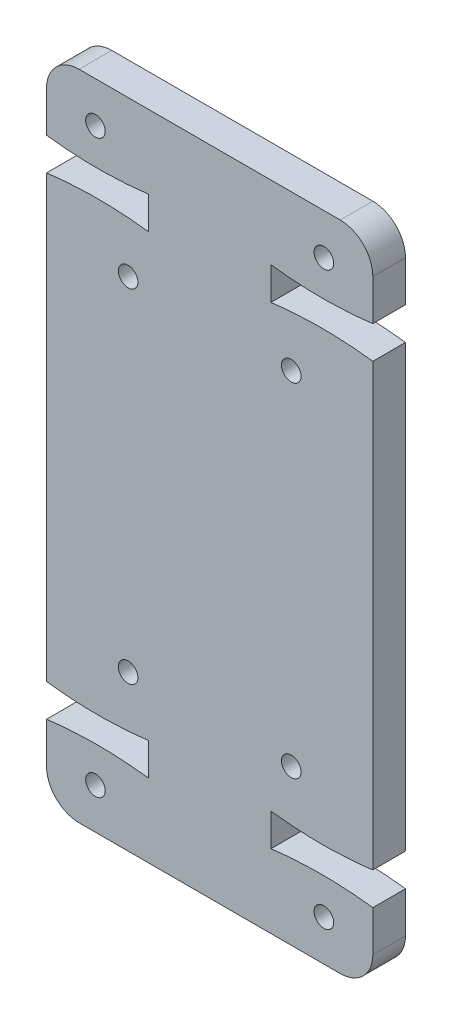
from build123d import *

# Parameters (mm, degrees)
SKETCH1_R               = 0.6
FINGER_PIP_BODY_DEPTH   = 2
FINGER_PIP_CONTOURING_R = 2


with BuildPart() as part:
    # Sketch1 → Finger PIP Body (new body)
    with BuildSketch(Plane.XY):
        with BuildLine():
            Line((0, 6.5), (0, 33.5))
            add(Edge.make_bspline(
                [(0, 33.5), (3.125, 33.9), (6.25, 33.5)],
                knots=[0, 0, 0, 1, 1, 1], degree=2))
            Line((6.25, 33.5), (6.25, 35.5))
            add(Edge.make_bspline(
                [(0, 35.5), (3.125, 35.1), (6.25, 35.5)],
                knots=[0, 0, 0, 1, 1, 1], degree=2))
            Line((0, 35.5), (0, 40))
            Line((0, 40), (20, 40))
            Line((20, 40), (20, 35.5))
            add(Edge.make_bspline(
                [(20, 35.5), (16.875, 35.1), (13.75, 35.5)],
                knots=[0, 0, 0, 1, 1, 1], degree=2))
            Line((13.75, 35.5), (13.75, 33.5))
            add(Edge.make_bspline(
                [(20, 33.5), (16.875, 33.9), (13.75, 33.5)],
                knots=[0, 0, 0, 1, 1, 1], degree=2))
            Line((20, 33.5), (20, 6.5))
            add(Edge.make_bspline(
                [(20, 6.5), (16.875, 6.1), (13.75, 6.5)],
                knots=[0, 0, 0, 1, 1, 1], degree=2))
            Line((13.75, 6.5), (13.75, 4.5))
            add(Edge.make_bspline(
                [(20, 4.5), (16.875, 4.9), (13.75, 4.5)],
                knots=[0, 0, 0, 1, 1, 1], degree=2))
            Line((20, 4.5), (20, 0))
            Line((20, 0), (0, 0))
            Line((0, 0), (0, 4.5))
            add(Edge.make_bspline(
                [(0, 4.5), (3.125, 4.9), (6.25, 4.5)],
                knots=[0, 0, 0, 1, 1, 1], degree=2))
            Line((6.25, 4.5), (6.25, 6.5))
            add(Edge.make_bspline(
                [(0, 6.5), (3.125, 6.1), (6.25, 6.5)],
                knots=[0, 0, 0, 1, 1, 1], degree=2))
        make_face()
        with Locations((3, 2.5)):
            Circle(SKETCH1_R, mode=Mode.SUBTRACT)
        with Locations((5, 9.5)):
            Circle(SKETCH1_R, mode=Mode.SUBTRACT)
        with Locations((5, 30.5)):
            Circle(SKETCH1_R, mode=Mode.SUBTRACT)
        with Locations((3, 37.5)):
            Circle(SKETCH1_R, mode=Mode.SUBTRACT)
        with Locations((17, 37.5)):
            Circle(SKETCH1_R, mode=Mode.SUBTRACT)
        with Locations((15, 30.5)):
            Circle(SKETCH1_R, mode=Mode.SUBTRACT)
        with Locations((15, 9.5)):
            Circle(SKETCH1_R, mode=Mode.SUBTRACT)
        with Locations((17, 2.5)):
            Circle(SKETCH1_R, mode=Mode.SUBTRACT)
    extrude(amount=FINGER_PIP_BODY_DEPTH)

    # Finger PIP Contouring
    finger_pip_contouring_edges = [part.edges().sort_by_distance(p)[0] for p in [
        (0, 40, 1),
        (20, 40, 1),
        (20, 0, 1),
        (0, 0, 1),
    ]]
    fillet(finger_pip_contouring_edges, radius=FINGER_PIP_CONTOURING_R)


solid = part.part
